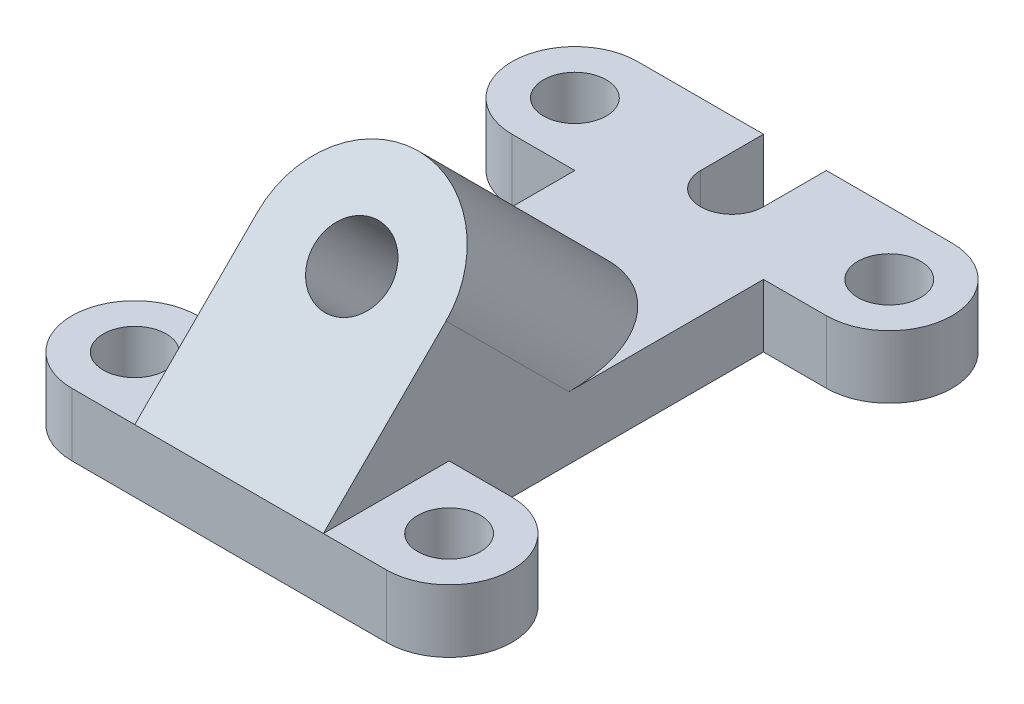
from build123d import *

# Parameters (mm, degrees)
SKETCH2_R           = 6.35
BOSS_EXTRUDE1_DEPTH = 12.7
BOSS_EXTRUDE2_REACH = 91.803
SKETCH4_R           = 7.62


with BuildPart() as part:
    # Sketch2 → Boss-Extrude1 (new body)
    with BuildSketch(Plane(origin=(0, 0, 0), x_dir=(1, 0, 0), z_dir=(0, 1, 0))):
        with BuildLine():
            Line((-63.5, 101.6), (-38.1, 101.6))
            Line((-38.1, 101.6), (-38.1, 88.9))
            ThreePointArc((-38.1, 88.9), (-31.75, 82.55), (-25.4, 88.9))
            Line((-25.4, 88.9), (-25.4, 101.6))
            Line((-25.4, 101.6), (0, 101.6))
            ThreePointArc((0, 101.6), (12.7, 88.9), (0, 76.2))
            Line((0, 76.2), (-12.7, 76.2))
            Line((-12.7, 76.2), (-12.7, 12.7))
            Line((-12.7, 12.7), (0, 12.7))
            ThreePointArc((0, 12.7), (12.7, 0), (0, -12.7))
            Line((0, -12.7), (-63.5, -12.7))
            ThreePointArc((-63.5, -12.7), (-76.2, 0), (-63.5, 12.7))
            Line((-63.5, 12.7), (-50.8, 12.7))
            Line((-50.8, 12.7), (-50.8, 76.2))
            Line((-50.8, 76.2), (-63.5, 76.2))
            ThreePointArc((-63.5, 76.2), (-76.2, 88.9), (-63.5, 101.6))
        make_face()
        Circle(SKETCH2_R, mode=Mode.SUBTRACT)
        with Locations((0, 88.9)):
            Circle(SKETCH2_R, mode=Mode.SUBTRACT)
        with Locations((-63.5, 0)):
            Circle(SKETCH2_R, mode=Mode.SUBTRACT)
        with Locations((-63.5, 88.9)):
            Circle(SKETCH2_R, mode=Mode.SUBTRACT)
    extrude(amount=BOSS_EXTRUDE1_DEPTH)

    # Sketch4 → Boss-Extrude2 (add, up to next)
    with BuildSketch(Plane(origin=(0, 12.7, 12.7), x_dir=(1, 0, 0), z_dir=(0, 0.707106781, 0.707106781)), mode=Mode.PRIVATE) as boss_extrude2_sk1:
        with BuildLine():
            Line((-50.8, 0), (-50.8, 35.052))
            ThreePointArc((-50.8, 35.052), (-31.75, 54.102), (-12.7, 35.052))
            Line((-12.7, 35.052), (-12.7, 0))
            Line((-12.7, 0), (-50.8, 0))
        make_face()
        with Locations((-31.75, 35.052)):
            Circle(SKETCH4_R, mode=Mode.SUBTRACT)
    boss_extrude2_tool1 = extrude(boss_extrude2_sk1.sketch, amount=-BOSS_EXTRUDE2_REACH, mode=Mode.PRIVATE) - part.part
    add(boss_extrude2_tool1.solids().sort_by_distance((-31.75, 29.771946, -4.371946))[0])


solid = part.part
